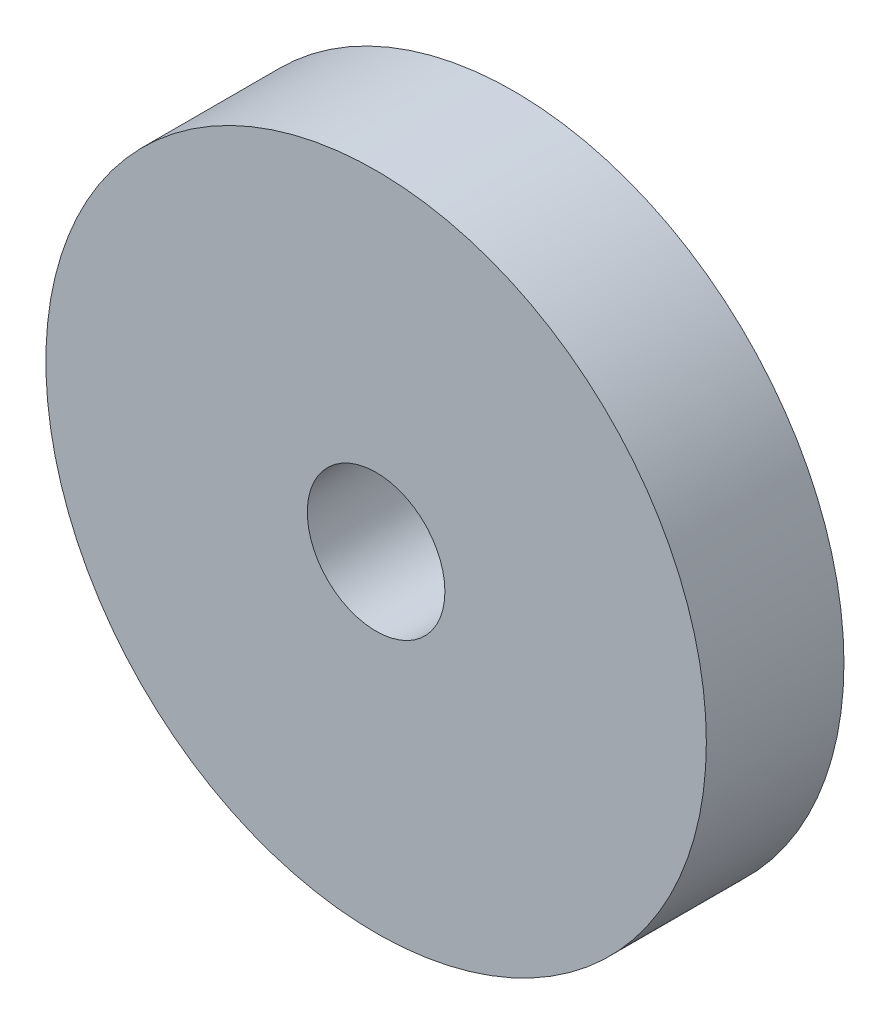
from build123d import *

# Parameters (mm, degrees)
SKETCH1_R           = 38.1
SKETCH1_R_2         = 7.9375
BOSS_EXTRUDE1_DEPTH = 15.875


with BuildPart() as part:
    # Sketch1 → Boss-Extrude1 (new body)
    with BuildSketch(Plane.XY):
        Circle(SKETCH1_R)
        Circle(SKETCH1_R_2, mode=Mode.SUBTRACT)
    extrude(amount=BOSS_EXTRUDE1_DEPTH)


solid = part.part
